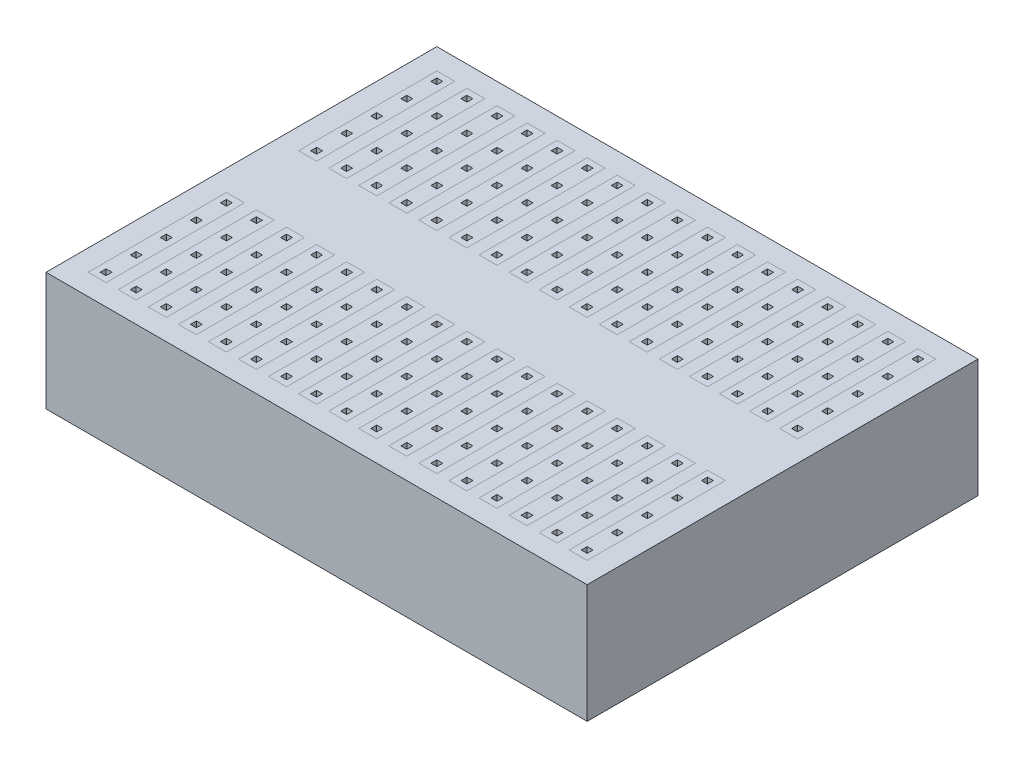
from build123d import *

# Parameters (mm, degrees)
SKETCH_PROTOBOARD_BODY_W        = 45.72
SKETCH_PROTOBOARD_BODY_H        = 33.02
PROTOBOARD_BODY_DEPTH           = 10
SKETCH_TERMINAL_STRIPS_W        = 1.52
SKETCH_TERMINAL_STRIPS_H        = 11.68
SPACE_FOR_TERMINAL_STRIPS_DEPTH = 8.4
SKETCH3_2_W                     = 1.52
SKETCH3_2_H                     = 11.68
TERMINAL_STRIPS_DEPTH           = 8.4
TERMINAL_STRIPS_2_DEPTH         = 8.4
TERMINAL_STRIPS_3_DEPTH         = 8.4
TERMINAL_STRIPS_4_DEPTH         = 8.4
TERMINAL_STRIPS_5_DEPTH         = 8.4
TERMINAL_STRIPS_6_DEPTH         = 8.4
TERMINAL_STRIPS_7_DEPTH         = 8.4
TERMINAL_STRIPS_8_DEPTH         = 8.4
TERMINAL_STRIPS_9_DEPTH         = 8.4
TERMINAL_STRIPS_10_DEPTH        = 8.4
TERMINAL_STRIPS_11_DEPTH        = 8.4
TERMINAL_STRIPS_12_DEPTH        = 8.4
TERMINAL_STRIPS_13_DEPTH        = 8.4
TERMINAL_STRIPS_14_DEPTH        = 8.4
TERMINAL_STRIPS_15_DEPTH        = 8.4
TERMINAL_STRIPS_16_DEPTH        = 8.4
TERMINAL_STRIPS_17_DEPTH        = 8.4
TERMINAL_STRIPS_18_DEPTH        = 8.4
TERMINAL_STRIPS_19_DEPTH        = 8.4
TERMINAL_STRIPS_20_DEPTH        = 8.4
TERMINAL_STRIPS_21_DEPTH        = 8.4
TERMINAL_STRIPS_22_DEPTH        = 8.4
TERMINAL_STRIPS_23_DEPTH        = 8.4
TERMINAL_STRIPS_24_DEPTH        = 8.4
TERMINAL_STRIPS_25_DEPTH        = 8.4
TERMINAL_STRIPS_26_DEPTH        = 8.4
TERMINAL_STRIPS_27_DEPTH        = 8.4
TERMINAL_STRIPS_28_DEPTH        = 8.4
TERMINAL_STRIPS_29_DEPTH        = 8.4
TERMINAL_STRIPS_30_DEPTH        = 8.4
TERMINAL_STRIPS_31_DEPTH        = 8.4
TERMINAL_STRIPS_32_DEPTH        = 8.4
TERMINAL_STRIPS_33_DEPTH        = 8.4
TERMINAL_STRIPS_34_DEPTH        = 8.4
SKETCH_PIN_HOLES_W              = 0.5
SKETCH_PIN_HOLES_H              = 0.5
PIN_HOLES_DEPTH                 = 7.9


with BuildPart() as part:
    # Sketch_ Protoboard Body → Protoboard Body (new body)
    with BuildSketch(Plane(origin=(0, 0, 0), x_dir=(1, 0, 0), z_dir=(0, 1, 0))):
        Rectangle(SKETCH_PROTOBOARD_BODY_W, SKETCH_PROTOBOARD_BODY_H)
    extrude(amount=-PROTOBOARD_BODY_DEPTH)

    # Sketch_ Terminal Strips → Space for Terminal Strips (cut)
    with BuildSketch(Plane(origin=(0, 0, 0), x_dir=(1, 0, 0), z_dir=(0, 1, 0))):
        with Locations((-17.78, -8.89)):
            Rectangle(SKETCH_TERMINAL_STRIPS_W, SKETCH_TERMINAL_STRIPS_H)
        with Locations((-20.32, -8.89)):
            Rectangle(SKETCH_TERMINAL_STRIPS_W, SKETCH_TERMINAL_STRIPS_H)
        with Locations((-15.24, -8.89)):
            Rectangle(SKETCH_TERMINAL_STRIPS_W, SKETCH_TERMINAL_STRIPS_H)
        with Locations((-12.7, -8.89)):
            Rectangle(SKETCH_TERMINAL_STRIPS_W, SKETCH_TERMINAL_STRIPS_H)
        with Locations((-10.16, -8.89)):
            Rectangle(SKETCH_TERMINAL_STRIPS_W, SKETCH_TERMINAL_STRIPS_H)
        with Locations((-7.62, -8.89)):
            Rectangle(SKETCH_TERMINAL_STRIPS_W, SKETCH_TERMINAL_STRIPS_H)
        with Locations((-5.08, -8.89)):
            Rectangle(SKETCH_TERMINAL_STRIPS_W, SKETCH_TERMINAL_STRIPS_H)
        with Locations((-2.54, -8.89)):
            Rectangle(SKETCH_TERMINAL_STRIPS_W, SKETCH_TERMINAL_STRIPS_H)
        with Locations((0, -8.89)):
            Rectangle(SKETCH_TERMINAL_STRIPS_W, SKETCH_TERMINAL_STRIPS_H)
        with Locations((2.54, -8.89)):
            Rectangle(SKETCH_TERMINAL_STRIPS_W, SKETCH_TERMINAL_STRIPS_H)
        with Locations((5.08, -8.89)):
            Rectangle(SKETCH_TERMINAL_STRIPS_W, SKETCH_TERMINAL_STRIPS_H)
        with Locations((7.62, -8.89)):
            Rectangle(SKETCH_TERMINAL_STRIPS_W, SKETCH_TERMINAL_STRIPS_H)
        with Locations((10.16, -8.89)):
            Rectangle(SKETCH_TERMINAL_STRIPS_W, SKETCH_TERMINAL_STRIPS_H)
        with Locations((12.7, -8.89)):
            Rectangle(SKETCH_TERMINAL_STRIPS_W, SKETCH_TERMINAL_STRIPS_H)
        with Locations((15.24, -8.89)):
            Rectangle(SKETCH_TERMINAL_STRIPS_W, SKETCH_TERMINAL_STRIPS_H)
        with Locations((17.78, -8.89)):
            Rectangle(SKETCH_TERMINAL_STRIPS_W, SKETCH_TERMINAL_STRIPS_H)
        with Locations((20.32, -8.89)):
            Rectangle(SKETCH_TERMINAL_STRIPS_W, SKETCH_TERMINAL_STRIPS_H)
        with Locations((-17.78, 8.89)):
            Rectangle(SKETCH_TERMINAL_STRIPS_W, SKETCH_TERMINAL_STRIPS_H)
        with Locations((-15.24, 8.89)):
            Rectangle(SKETCH_TERMINAL_STRIPS_W, SKETCH_TERMINAL_STRIPS_H)
        with Locations((-12.7, 8.89)):
            Rectangle(SKETCH_TERMINAL_STRIPS_W, SKETCH_TERMINAL_STRIPS_H)
        with Locations((-10.16, 8.89)):
            Rectangle(SKETCH_TERMINAL_STRIPS_W, SKETCH_TERMINAL_STRIPS_H)
        with Locations((-7.62, 8.89)):
            Rectangle(SKETCH_TERMINAL_STRIPS_W, SKETCH_TERMINAL_STRIPS_H)
        with Locations((-5.08, 8.89)):
            Rectangle(SKETCH_TERMINAL_STRIPS_W, SKETCH_TERMINAL_STRIPS_H)
        with Locations((-2.54, 8.89)):
            Rectangle(SKETCH_TERMINAL_STRIPS_W, SKETCH_TERMINAL_STRIPS_H)
        with Locations((0, 8.89)):
            Rectangle(SKETCH_TERMINAL_STRIPS_W, SKETCH_TERMINAL_STRIPS_H)
        with Locations((2.54, 8.89)):
            Rectangle(SKETCH_TERMINAL_STRIPS_W, SKETCH_TERMINAL_STRIPS_H)
        with Locations((5.08, 8.89)):
            Rectangle(SKETCH_TERMINAL_STRIPS_W, SKETCH_TERMINAL_STRIPS_H)
        with Locations((7.62, 8.89)):
            Rectangle(SKETCH_TERMINAL_STRIPS_W, SKETCH_TERMINAL_STRIPS_H)
        with Locations((10.16, 8.89)):
            Rectangle(SKETCH_TERMINAL_STRIPS_W, SKETCH_TERMINAL_STRIPS_H)
        with Locations((12.7, 8.89)):
            Rectangle(SKETCH_TERMINAL_STRIPS_W, SKETCH_TERMINAL_STRIPS_H)
        with Locations((15.24, 8.89)):
            Rectangle(SKETCH_TERMINAL_STRIPS_W, SKETCH_TERMINAL_STRIPS_H)
        with Locations((17.78, 8.89)):
            Rectangle(SKETCH_TERMINAL_STRIPS_W, SKETCH_TERMINAL_STRIPS_H)
        with Locations((20.32, 8.89)):
            Rectangle(SKETCH_TERMINAL_STRIPS_W, SKETCH_TERMINAL_STRIPS_H)
        with Locations((-20.32, 8.89)):
            Rectangle(SKETCH_TERMINAL_STRIPS_W, SKETCH_TERMINAL_STRIPS_H)
    extrude(amount=-SPACE_FOR_TERMINAL_STRIPS_DEPTH, mode=Mode.SUBTRACT)


with BuildPart() as body_2:
    # Sketch3_2 → Terminal Strips (new body)
    with BuildSketch(Plane(origin=(0, 0, 0), x_dir=(1, 0, 0), z_dir=(0, 1, 0))):
        with Locations((-17.78, -8.89)):
            Rectangle(SKETCH3_2_W, SKETCH3_2_H)
    extrude(amount=-TERMINAL_STRIPS_DEPTH)


with BuildPart() as body_3:
    # Sketch3_2 → Terminal Strips 2 (new body)
    with BuildSketch(Plane(origin=(0, 0, 0), x_dir=(1, 0, 0), z_dir=(0, 1, 0))):
        with Locations((-20.32, -8.89)):
            Rectangle(SKETCH3_2_W, SKETCH3_2_H)
    extrude(amount=-TERMINAL_STRIPS_2_DEPTH)


with BuildPart() as body_4:
    # Sketch3_2 → Terminal Strips 3 (new body)
    with BuildSketch(Plane(origin=(0, 0, 0), x_dir=(1, 0, 0), z_dir=(0, 1, 0))):
        with Locations((-15.24, -8.89)):
            Rectangle(SKETCH3_2_W, SKETCH3_2_H)
    extrude(amount=-TERMINAL_STRIPS_3_DEPTH)


with BuildPart() as body_5:
    # Sketch3_2 → Terminal Strips 4 (new body)
    with BuildSketch(Plane(origin=(0, 0, 0), x_dir=(1, 0, 0), z_dir=(0, 1, 0))):
        with Locations((-12.7, -8.89)):
            Rectangle(SKETCH3_2_W, SKETCH3_2_H)
    extrude(amount=-TERMINAL_STRIPS_4_DEPTH)


with BuildPart() as body_6:
    # Sketch3_2 → Terminal Strips 5 (new body)
    with BuildSketch(Plane(origin=(0, 0, 0), x_dir=(1, 0, 0), z_dir=(0, 1, 0))):
        with Locations((-10.16, -8.89)):
            Rectangle(SKETCH3_2_W, SKETCH3_2_H)
    extrude(amount=-TERMINAL_STRIPS_5_DEPTH)


with BuildPart() as body_7:
    # Sketch3_2 → Terminal Strips 6 (new body)
    with BuildSketch(Plane(origin=(0, 0, 0), x_dir=(1, 0, 0), z_dir=(0, 1, 0))):
        with Locations((-7.62, -8.89)):
            Rectangle(SKETCH3_2_W, SKETCH3_2_H)
    extrude(amount=-TERMINAL_STRIPS_6_DEPTH)


with BuildPart() as body_8:
    # Sketch3_2 → Terminal Strips 7 (new body)
    with BuildSketch(Plane(origin=(0, 0, 0), x_dir=(1, 0, 0), z_dir=(0, 1, 0))):
        with Locations((-5.08, -8.89)):
            Rectangle(SKETCH3_2_W, SKETCH3_2_H)
    extrude(amount=-TERMINAL_STRIPS_7_DEPTH)


with BuildPart() as body_9:
    # Sketch3_2 → Terminal Strips 8 (new body)
    with BuildSketch(Plane(origin=(0, 0, 0), x_dir=(1, 0, 0), z_dir=(0, 1, 0))):
        with Locations((-2.54, -8.89)):
            Rectangle(SKETCH3_2_W, SKETCH3_2_H)
    extrude(amount=-TERMINAL_STRIPS_8_DEPTH)


with BuildPart() as body_10:
    # Sketch3_2 → Terminal Strips 9 (new body)
    with BuildSketch(Plane(origin=(0, 0, 0), x_dir=(1, 0, 0), z_dir=(0, 1, 0))):
        with Locations((0, -8.89)):
            Rectangle(SKETCH3_2_W, SKETCH3_2_H)
    extrude(amount=-TERMINAL_STRIPS_9_DEPTH)


with BuildPart() as body_11:
    # Sketch3_2 → Terminal Strips 10 (new body)
    with BuildSketch(Plane(origin=(0, 0, 0), x_dir=(1, 0, 0), z_dir=(0, 1, 0))):
        with Locations((2.54, -8.89)):
            Rectangle(SKETCH3_2_W, SKETCH3_2_H)
    extrude(amount=-TERMINAL_STRIPS_10_DEPTH)


with BuildPart() as body_12:
    # Sketch3_2 → Terminal Strips 11 (new body)
    with BuildSketch(Plane(origin=(0, 0, 0), x_dir=(1, 0, 0), z_dir=(0, 1, 0))):
        with Locations((5.08, -8.89)):
            Rectangle(SKETCH3_2_W, SKETCH3_2_H)
    extrude(amount=-TERMINAL_STRIPS_11_DEPTH)


with BuildPart() as body_13:
    # Sketch3_2 → Terminal Strips 12 (new body)
    with BuildSketch(Plane(origin=(0, 0, 0), x_dir=(1, 0, 0), z_dir=(0, 1, 0))):
        with Locations((7.62, -8.89)):
            Rectangle(SKETCH3_2_W, SKETCH3_2_H)
    extrude(amount=-TERMINAL_STRIPS_12_DEPTH)


with BuildPart() as body_14:
    # Sketch3_2 → Terminal Strips 13 (new body)
    with BuildSketch(Plane(origin=(0, 0, 0), x_dir=(1, 0, 0), z_dir=(0, 1, 0))):
        with Locations((10.16, -8.89)):
            Rectangle(SKETCH3_2_W, SKETCH3_2_H)
    extrude(amount=-TERMINAL_STRIPS_13_DEPTH)


with BuildPart() as body_15:
    # Sketch3_2 → Terminal Strips 14 (new body)
    with BuildSketch(Plane(origin=(0, 0, 0), x_dir=(1, 0, 0), z_dir=(0, 1, 0))):
        with Locations((12.7, -8.89)):
            Rectangle(SKETCH3_2_W, SKETCH3_2_H)
    extrude(amount=-TERMINAL_STRIPS_14_DEPTH)


with BuildPart() as body_16:
    # Sketch3_2 → Terminal Strips 15 (new body)
    with BuildSketch(Plane(origin=(0, 0, 0), x_dir=(1, 0, 0), z_dir=(0, 1, 0))):
        with Locations((15.24, -8.89)):
            Rectangle(SKETCH3_2_W, SKETCH3_2_H)
    extrude(amount=-TERMINAL_STRIPS_15_DEPTH)


with BuildPart() as body_17:
    # Sketch3_2 → Terminal Strips 16 (new body)
    with BuildSketch(Plane(origin=(0, 0, 0), x_dir=(1, 0, 0), z_dir=(0, 1, 0))):
        with Locations((17.78, -8.89)):
            Rectangle(SKETCH3_2_W, SKETCH3_2_H)
    extrude(amount=-TERMINAL_STRIPS_16_DEPTH)


with BuildPart() as body_18:
    # Sketch3_2 → Terminal Strips 17 (new body)
    with BuildSketch(Plane(origin=(0, 0, 0), x_dir=(1, 0, 0), z_dir=(0, 1, 0))):
        with Locations((20.32, -8.89)):
            Rectangle(SKETCH3_2_W, SKETCH3_2_H)
    extrude(amount=-TERMINAL_STRIPS_17_DEPTH)


with BuildPart() as body_19:
    # Sketch3_2 → Terminal Strips 18 (new body)
    with BuildSketch(Plane(origin=(0, 0, 0), x_dir=(1, 0, 0), z_dir=(0, 1, 0))):
        with Locations((-17.78, 8.89)):
            Rectangle(SKETCH3_2_W, SKETCH3_2_H)
    extrude(amount=-TERMINAL_STRIPS_18_DEPTH)


with BuildPart() as body_20:
    # Sketch3_2 → Terminal Strips 19 (new body)
    with BuildSketch(Plane(origin=(0, 0, 0), x_dir=(1, 0, 0), z_dir=(0, 1, 0))):
        with Locations((-15.24, 8.89)):
            Rectangle(SKETCH3_2_W, SKETCH3_2_H)
    extrude(amount=-TERMINAL_STRIPS_19_DEPTH)


with BuildPart() as body_21:
    # Sketch3_2 → Terminal Strips 20 (new body)
    with BuildSketch(Plane(origin=(0, 0, 0), x_dir=(1, 0, 0), z_dir=(0, 1, 0))):
        with Locations((-12.7, 8.89)):
            Rectangle(SKETCH3_2_W, SKETCH3_2_H)
    extrude(amount=-TERMINAL_STRIPS_20_DEPTH)


with BuildPart() as body_22:
    # Sketch3_2 → Terminal Strips 21 (new body)
    with BuildSketch(Plane(origin=(0, 0, 0), x_dir=(1, 0, 0), z_dir=(0, 1, 0))):
        with Locations((-10.16, 8.89)):
            Rectangle(SKETCH3_2_W, SKETCH3_2_H)
    extrude(amount=-TERMINAL_STRIPS_21_DEPTH)


with BuildPart() as body_23:
    # Sketch3_2 → Terminal Strips 22 (new body)
    with BuildSketch(Plane(origin=(0, 0, 0), x_dir=(1, 0, 0), z_dir=(0, 1, 0))):
        with Locations((-7.62, 8.89)):
            Rectangle(SKETCH3_2_W, SKETCH3_2_H)
    extrude(amount=-TERMINAL_STRIPS_22_DEPTH)


with BuildPart() as body_24:
    # Sketch3_2 → Terminal Strips 23 (new body)
    with BuildSketch(Plane(origin=(0, 0, 0), x_dir=(1, 0, 0), z_dir=(0, 1, 0))):
        with Locations((-5.08, 8.89)):
            Rectangle(SKETCH3_2_W, SKETCH3_2_H)
    extrude(amount=-TERMINAL_STRIPS_23_DEPTH)


with BuildPart() as body_25:
    # Sketch3_2 → Terminal Strips 24 (new body)
    with BuildSketch(Plane(origin=(0, 0, 0), x_dir=(1, 0, 0), z_dir=(0, 1, 0))):
        with Locations((-2.54, 8.89)):
            Rectangle(SKETCH3_2_W, SKETCH3_2_H)
    extrude(amount=-TERMINAL_STRIPS_24_DEPTH)


with BuildPart() as body_26:
    # Sketch3_2 → Terminal Strips 25 (new body)
    with BuildSketch(Plane(origin=(0, 0, 0), x_dir=(1, 0, 0), z_dir=(0, 1, 0))):
        with Locations((0, 8.89)):
            Rectangle(SKETCH3_2_W, SKETCH3_2_H)
    extrude(amount=-TERMINAL_STRIPS_25_DEPTH)


with BuildPart() as body_27:
    # Sketch3_2 → Terminal Strips 26 (new body)
    with BuildSketch(Plane(origin=(0, 0, 0), x_dir=(1, 0, 0), z_dir=(0, 1, 0))):
        with Locations((2.54, 8.89)):
            Rectangle(SKETCH3_2_W, SKETCH3_2_H)
    extrude(amount=-TERMINAL_STRIPS_26_DEPTH)


with BuildPart() as body_28:
    # Sketch3_2 → Terminal Strips 27 (new body)
    with BuildSketch(Plane(origin=(0, 0, 0), x_dir=(1, 0, 0), z_dir=(0, 1, 0))):
        with Locations((5.08, 8.89)):
            Rectangle(SKETCH3_2_W, SKETCH3_2_H)
    extrude(amount=-TERMINAL_STRIPS_27_DEPTH)


with BuildPart() as body_29:
    # Sketch3_2 → Terminal Strips 28 (new body)
    with BuildSketch(Plane(origin=(0, 0, 0), x_dir=(1, 0, 0), z_dir=(0, 1, 0))):
        with Locations((7.62, 8.89)):
            Rectangle(SKETCH3_2_W, SKETCH3_2_H)
    extrude(amount=-TERMINAL_STRIPS_28_DEPTH)


with BuildPart() as body_30:
    # Sketch3_2 → Terminal Strips 29 (new body)
    with BuildSketch(Plane(origin=(0, 0, 0), x_dir=(1, 0, 0), z_dir=(0, 1, 0))):
        with Locations((10.16, 8.89)):
            Rectangle(SKETCH3_2_W, SKETCH3_2_H)
    extrude(amount=-TERMINAL_STRIPS_29_DEPTH)


with BuildPart() as body_31:
    # Sketch3_2 → Terminal Strips 30 (new body)
    with BuildSketch(Plane(origin=(0, 0, 0), x_dir=(1, 0, 0), z_dir=(0, 1, 0))):
        with Locations((12.7, 8.89)):
            Rectangle(SKETCH3_2_W, SKETCH3_2_H)
    extrude(amount=-TERMINAL_STRIPS_30_DEPTH)


with BuildPart() as body_32:
    # Sketch3_2 → Terminal Strips 31 (new body)
    with BuildSketch(Plane(origin=(0, 0, 0), x_dir=(1, 0, 0), z_dir=(0, 1, 0))):
        with Locations((15.24, 8.89)):
            Rectangle(SKETCH3_2_W, SKETCH3_2_H)
    extrude(amount=-TERMINAL_STRIPS_31_DEPTH)


with BuildPart() as body_33:
    # Sketch3_2 → Terminal Strips 32 (new body)
    with BuildSketch(Plane(origin=(0, 0, 0), x_dir=(1, 0, 0), z_dir=(0, 1, 0))):
        with Locations((17.78, 8.89)):
            Rectangle(SKETCH3_2_W, SKETCH3_2_H)
    extrude(amount=-TERMINAL_STRIPS_32_DEPTH)


with BuildPart() as body_34:
    # Sketch3_2 → Terminal Strips 33 (new body)
    with BuildSketch(Plane(origin=(0, 0, 0), x_dir=(1, 0, 0), z_dir=(0, 1, 0))):
        with Locations((20.32, 8.89)):
            Rectangle(SKETCH3_2_W, SKETCH3_2_H)
    extrude(amount=-TERMINAL_STRIPS_33_DEPTH)


with BuildPart() as body_35:
    # Sketch3_2 → Terminal Strips 34 (new body)
    with BuildSketch(Plane(origin=(0, 0, 0), x_dir=(1, 0, 0), z_dir=(0, 1, 0))):
        with Locations((-20.32, 8.89)):
            Rectangle(SKETCH3_2_W, SKETCH3_2_H)
    extrude(amount=-TERMINAL_STRIPS_34_DEPTH)


with BuildPart() as pin_holes_tool:
    # Sketch_ Pin Holes → Pin Holes (new body)
    with BuildSketch(Plane(origin=(0, 0, 0), x_dir=(1, 0, 0), z_dir=(0, 1, 0))):
        with Locations((-20.32, -13.97)):
            Rectangle(SKETCH_PIN_HOLES_W, SKETCH_PIN_HOLES_H)
        with Locations((-20.32, -11.43)):
            Rectangle(SKETCH_PIN_HOLES_W, SKETCH_PIN_HOLES_H)
        with Locations((-20.32, -8.89)):
            Rectangle(SKETCH_PIN_HOLES_W, SKETCH_PIN_HOLES_H)
        with Locations((-20.32, -6.35)):
            Rectangle(SKETCH_PIN_HOLES_W, SKETCH_PIN_HOLES_H)
        with Locations((-20.32, -3.81)):
            Rectangle(SKETCH_PIN_HOLES_W, SKETCH_PIN_HOLES_H)
        with Locations((-20.32, 3.81)):
            Rectangle(SKETCH_PIN_HOLES_W, SKETCH_PIN_HOLES_H)
        with Locations((-20.32, 6.35)):
            Rectangle(SKETCH_PIN_HOLES_W, SKETCH_PIN_HOLES_H)
        with Locations((-20.32, 8.89)):
            Rectangle(SKETCH_PIN_HOLES_W, SKETCH_PIN_HOLES_H)
        with Locations((-20.32, 11.43)):
            Rectangle(SKETCH_PIN_HOLES_W, SKETCH_PIN_HOLES_H)
        with Locations((-20.32, 13.97)):
            Rectangle(SKETCH_PIN_HOLES_W, SKETCH_PIN_HOLES_H)
        with Locations((-17.78, -13.97)):
            Rectangle(SKETCH_PIN_HOLES_W, SKETCH_PIN_HOLES_H)
        with Locations((-17.78, -11.43)):
            Rectangle(SKETCH_PIN_HOLES_W, SKETCH_PIN_HOLES_H)
        with Locations((-17.78, -8.89)):
            Rectangle(SKETCH_PIN_HOLES_W, SKETCH_PIN_HOLES_H)
        with Locations((-17.78, -6.35)):
            Rectangle(SKETCH_PIN_HOLES_W, SKETCH_PIN_HOLES_H)
        with Locations((-17.78, -3.81)):
            Rectangle(SKETCH_PIN_HOLES_W, SKETCH_PIN_HOLES_H)
        with Locations((-17.78, 3.81)):
            Rectangle(SKETCH_PIN_HOLES_W, SKETCH_PIN_HOLES_H)
        with Locations((-17.78, 6.35)):
            Rectangle(SKETCH_PIN_HOLES_W, SKETCH_PIN_HOLES_H)
        with Locations((-17.78, 8.89)):
            Rectangle(SKETCH_PIN_HOLES_W, SKETCH_PIN_HOLES_H)
        with Locations((-17.78, 11.43)):
            Rectangle(SKETCH_PIN_HOLES_W, SKETCH_PIN_HOLES_H)
        with Locations((-17.78, 13.97)):
            Rectangle(SKETCH_PIN_HOLES_W, SKETCH_PIN_HOLES_H)
        with Locations((-15.24, -13.97)):
            Rectangle(SKETCH_PIN_HOLES_W, SKETCH_PIN_HOLES_H)
        with Locations((-15.24, -11.43)):
            Rectangle(SKETCH_PIN_HOLES_W, SKETCH_PIN_HOLES_H)
        with Locations((-15.24, -8.89)):
            Rectangle(SKETCH_PIN_HOLES_W, SKETCH_PIN_HOLES_H)
        with Locations((-15.24, -6.35)):
            Rectangle(SKETCH_PIN_HOLES_W, SKETCH_PIN_HOLES_H)
        with Locations((-15.24, -3.81)):
            Rectangle(SKETCH_PIN_HOLES_W, SKETCH_PIN_HOLES_H)
        with Locations((-15.24, 3.81)):
            Rectangle(SKETCH_PIN_HOLES_W, SKETCH_PIN_HOLES_H)
        with Locations((-15.24, 6.35)):
            Rectangle(SKETCH_PIN_HOLES_W, SKETCH_PIN_HOLES_H)
        with Locations((-15.24, 8.89)):
            Rectangle(SKETCH_PIN_HOLES_W, SKETCH_PIN_HOLES_H)
        with Locations((-15.24, 11.43)):
            Rectangle(SKETCH_PIN_HOLES_W, SKETCH_PIN_HOLES_H)
        with Locations((-15.24, 13.97)):
            Rectangle(SKETCH_PIN_HOLES_W, SKETCH_PIN_HOLES_H)
        with Locations((-12.7, -13.97)):
            Rectangle(SKETCH_PIN_HOLES_W, SKETCH_PIN_HOLES_H)
        with Locations((-12.7, -11.43)):
            Rectangle(SKETCH_PIN_HOLES_W, SKETCH_PIN_HOLES_H)
        with Locations((-12.7, -8.89)):
            Rectangle(SKETCH_PIN_HOLES_W, SKETCH_PIN_HOLES_H)
        with Locations((-12.7, -6.35)):
            Rectangle(SKETCH_PIN_HOLES_W, SKETCH_PIN_HOLES_H)
        with Locations((-12.7, -3.81)):
            Rectangle(SKETCH_PIN_HOLES_W, SKETCH_PIN_HOLES_H)
        with Locations((-12.7, 3.81)):
            Rectangle(SKETCH_PIN_HOLES_W, SKETCH_PIN_HOLES_H)
        with Locations((-12.7, 6.35)):
            Rectangle(SKETCH_PIN_HOLES_W, SKETCH_PIN_HOLES_H)
        with Locations((-12.7, 8.89)):
            Rectangle(SKETCH_PIN_HOLES_W, SKETCH_PIN_HOLES_H)
        with Locations((-12.7, 11.43)):
            Rectangle(SKETCH_PIN_HOLES_W, SKETCH_PIN_HOLES_H)
        with Locations((-12.7, 13.97)):
            Rectangle(SKETCH_PIN_HOLES_W, SKETCH_PIN_HOLES_H)
        with Locations((-10.16, -13.97)):
            Rectangle(SKETCH_PIN_HOLES_W, SKETCH_PIN_HOLES_H)
        with Locations((-10.16, -11.43)):
            Rectangle(SKETCH_PIN_HOLES_W, SKETCH_PIN_HOLES_H)
        with Locations((-10.16, -8.89)):
            Rectangle(SKETCH_PIN_HOLES_W, SKETCH_PIN_HOLES_H)
        with Locations((-10.16, -6.35)):
            Rectangle(SKETCH_PIN_HOLES_W, SKETCH_PIN_HOLES_H)
        with Locations((-10.16, -3.81)):
            Rectangle(SKETCH_PIN_HOLES_W, SKETCH_PIN_HOLES_H)
        with Locations((-10.16, 3.81)):
            Rectangle(SKETCH_PIN_HOLES_W, SKETCH_PIN_HOLES_H)
        with Locations((-10.16, 6.35)):
            Rectangle(SKETCH_PIN_HOLES_W, SKETCH_PIN_HOLES_H)
        with Locations((-10.16, 8.89)):
            Rectangle(SKETCH_PIN_HOLES_W, SKETCH_PIN_HOLES_H)
        with Locations((-10.16, 11.43)):
            Rectangle(SKETCH_PIN_HOLES_W, SKETCH_PIN_HOLES_H)
        with Locations((-10.16, 13.97)):
            Rectangle(SKETCH_PIN_HOLES_W, SKETCH_PIN_HOLES_H)
        with Locations((-7.62, -13.97)):
            Rectangle(SKETCH_PIN_HOLES_W, SKETCH_PIN_HOLES_H)
        with Locations((-7.62, -11.43)):
            Rectangle(SKETCH_PIN_HOLES_W, SKETCH_PIN_HOLES_H)
        with Locations((-7.62, -8.89)):
            Rectangle(SKETCH_PIN_HOLES_W, SKETCH_PIN_HOLES_H)
        with Locations((-7.62, -6.35)):
            Rectangle(SKETCH_PIN_HOLES_W, SKETCH_PIN_HOLES_H)
        with Locations((-7.62, -3.81)):
            Rectangle(SKETCH_PIN_HOLES_W, SKETCH_PIN_HOLES_H)
        with Locations((-7.62, 3.81)):
            Rectangle(SKETCH_PIN_HOLES_W, SKETCH_PIN_HOLES_H)
        with Locations((-7.62, 6.35)):
            Rectangle(SKETCH_PIN_HOLES_W, SKETCH_PIN_HOLES_H)
        with Locations((-7.62, 8.89)):
            Rectangle(SKETCH_PIN_HOLES_W, SKETCH_PIN_HOLES_H)
        with Locations((-7.62, 11.43)):
            Rectangle(SKETCH_PIN_HOLES_W, SKETCH_PIN_HOLES_H)
        with Locations((-7.62, 13.97)):
            Rectangle(SKETCH_PIN_HOLES_W, SKETCH_PIN_HOLES_H)
        with Locations((-5.08, -13.97)):
            Rectangle(SKETCH_PIN_HOLES_W, SKETCH_PIN_HOLES_H)
        with Locations((-5.08, -11.43)):
            Rectangle(SKETCH_PIN_HOLES_W, SKETCH_PIN_HOLES_H)
        with Locations((-5.08, -8.89)):
            Rectangle(SKETCH_PIN_HOLES_W, SKETCH_PIN_HOLES_H)
        with Locations((-5.08, -6.35)):
            Rectangle(SKETCH_PIN_HOLES_W, SKETCH_PIN_HOLES_H)
        with Locations((-5.08, -3.81)):
            Rectangle(SKETCH_PIN_HOLES_W, SKETCH_PIN_HOLES_H)
        with Locations((-5.08, 3.81)):
            Rectangle(SKETCH_PIN_HOLES_W, SKETCH_PIN_HOLES_H)
        with Locations((-5.08, 6.35)):
            Rectangle(SKETCH_PIN_HOLES_W, SKETCH_PIN_HOLES_H)
        with Locations((-5.08, 8.89)):
            Rectangle(SKETCH_PIN_HOLES_W, SKETCH_PIN_HOLES_H)
        with Locations((-5.08, 11.43)):
            Rectangle(SKETCH_PIN_HOLES_W, SKETCH_PIN_HOLES_H)
        with Locations((-5.08, 13.97)):
            Rectangle(SKETCH_PIN_HOLES_W, SKETCH_PIN_HOLES_H)
        with Locations((-2.54, -13.97)):
            Rectangle(SKETCH_PIN_HOLES_W, SKETCH_PIN_HOLES_H)
        with Locations((-2.54, -11.43)):
            Rectangle(SKETCH_PIN_HOLES_W, SKETCH_PIN_HOLES_H)
        with Locations((-2.54, -8.89)):
            Rectangle(SKETCH_PIN_HOLES_W, SKETCH_PIN_HOLES_H)
        with Locations((-2.54, -6.35)):
            Rectangle(SKETCH_PIN_HOLES_W, SKETCH_PIN_HOLES_H)
        with Locations((-2.54, -3.81)):
            Rectangle(SKETCH_PIN_HOLES_W, SKETCH_PIN_HOLES_H)
        with Locations((-2.54, 3.81)):
            Rectangle(SKETCH_PIN_HOLES_W, SKETCH_PIN_HOLES_H)
        with Locations((-2.54, 6.35)):
            Rectangle(SKETCH_PIN_HOLES_W, SKETCH_PIN_HOLES_H)
        with Locations((-2.54, 8.89)):
            Rectangle(SKETCH_PIN_HOLES_W, SKETCH_PIN_HOLES_H)
        with Locations((-2.54, 11.43)):
            Rectangle(SKETCH_PIN_HOLES_W, SKETCH_PIN_HOLES_H)
        with Locations((-2.54, 13.97)):
            Rectangle(SKETCH_PIN_HOLES_W, SKETCH_PIN_HOLES_H)
        with Locations((0, -13.97)):
            Rectangle(SKETCH_PIN_HOLES_W, SKETCH_PIN_HOLES_H)
        with Locations((0, -11.43)):
            Rectangle(SKETCH_PIN_HOLES_W, SKETCH_PIN_HOLES_H)
        with Locations((0, -8.89)):
            Rectangle(SKETCH_PIN_HOLES_W, SKETCH_PIN_HOLES_H)
        with Locations((0, -6.35)):
            Rectangle(SKETCH_PIN_HOLES_W, SKETCH_PIN_HOLES_H)
        with Locations((0, -3.81)):
            Rectangle(SKETCH_PIN_HOLES_W, SKETCH_PIN_HOLES_H)
        with Locations((0, 3.81)):
            Rectangle(SKETCH_PIN_HOLES_W, SKETCH_PIN_HOLES_H)
        with Locations((0, 6.35)):
            Rectangle(SKETCH_PIN_HOLES_W, SKETCH_PIN_HOLES_H)
        with Locations((0, 8.89)):
            Rectangle(SKETCH_PIN_HOLES_W, SKETCH_PIN_HOLES_H)
        with Locations((0, 11.43)):
            Rectangle(SKETCH_PIN_HOLES_W, SKETCH_PIN_HOLES_H)
        with Locations((0, 13.97)):
            Rectangle(SKETCH_PIN_HOLES_W, SKETCH_PIN_HOLES_H)
        with Locations((2.54, -13.97)):
            Rectangle(SKETCH_PIN_HOLES_W, SKETCH_PIN_HOLES_H)
        with Locations((2.54, -11.43)):
            Rectangle(SKETCH_PIN_HOLES_W, SKETCH_PIN_HOLES_H)
        with Locations((2.54, -8.89)):
            Rectangle(SKETCH_PIN_HOLES_W, SKETCH_PIN_HOLES_H)
        with Locations((2.54, -6.35)):
            Rectangle(SKETCH_PIN_HOLES_W, SKETCH_PIN_HOLES_H)
        with Locations((2.54, -3.81)):
            Rectangle(SKETCH_PIN_HOLES_W, SKETCH_PIN_HOLES_H)
        with Locations((2.54, 3.81)):
            Rectangle(SKETCH_PIN_HOLES_W, SKETCH_PIN_HOLES_H)
        with Locations((2.54, 6.35)):
            Rectangle(SKETCH_PIN_HOLES_W, SKETCH_PIN_HOLES_H)
        with Locations((2.54, 8.89)):
            Rectangle(SKETCH_PIN_HOLES_W, SKETCH_PIN_HOLES_H)
        with Locations((2.54, 11.43)):
            Rectangle(SKETCH_PIN_HOLES_W, SKETCH_PIN_HOLES_H)
        with Locations((2.54, 13.97)):
            Rectangle(SKETCH_PIN_HOLES_W, SKETCH_PIN_HOLES_H)
        with Locations((5.08, -13.97)):
            Rectangle(SKETCH_PIN_HOLES_W, SKETCH_PIN_HOLES_H)
        with Locations((5.08, -11.43)):
            Rectangle(SKETCH_PIN_HOLES_W, SKETCH_PIN_HOLES_H)
        with Locations((5.08, -8.89)):
            Rectangle(SKETCH_PIN_HOLES_W, SKETCH_PIN_HOLES_H)
        with Locations((5.08, -6.35)):
            Rectangle(SKETCH_PIN_HOLES_W, SKETCH_PIN_HOLES_H)
        with Locations((5.08, -3.81)):
            Rectangle(SKETCH_PIN_HOLES_W, SKETCH_PIN_HOLES_H)
        with Locations((5.08, 3.81)):
            Rectangle(SKETCH_PIN_HOLES_W, SKETCH_PIN_HOLES_H)
        with Locations((5.08, 6.35)):
            Rectangle(SKETCH_PIN_HOLES_W, SKETCH_PIN_HOLES_H)
        with Locations((5.08, 8.89)):
            Rectangle(SKETCH_PIN_HOLES_W, SKETCH_PIN_HOLES_H)
        with Locations((5.08, 11.43)):
            Rectangle(SKETCH_PIN_HOLES_W, SKETCH_PIN_HOLES_H)
        with Locations((5.08, 13.97)):
            Rectangle(SKETCH_PIN_HOLES_W, SKETCH_PIN_HOLES_H)
        with Locations((7.62, -13.97)):
            Rectangle(SKETCH_PIN_HOLES_W, SKETCH_PIN_HOLES_H)
        with Locations((7.62, -11.43)):
            Rectangle(SKETCH_PIN_HOLES_W, SKETCH_PIN_HOLES_H)
        with Locations((7.62, -8.89)):
            Rectangle(SKETCH_PIN_HOLES_W, SKETCH_PIN_HOLES_H)
        with Locations((7.62, -6.35)):
            Rectangle(SKETCH_PIN_HOLES_W, SKETCH_PIN_HOLES_H)
        with Locations((7.62, -3.81)):
            Rectangle(SKETCH_PIN_HOLES_W, SKETCH_PIN_HOLES_H)
        with Locations((7.62, 3.81)):
            Rectangle(SKETCH_PIN_HOLES_W, SKETCH_PIN_HOLES_H)
        with Locations((7.62, 6.35)):
            Rectangle(SKETCH_PIN_HOLES_W, SKETCH_PIN_HOLES_H)
        with Locations((7.62, 8.89)):
            Rectangle(SKETCH_PIN_HOLES_W, SKETCH_PIN_HOLES_H)
        with Locations((7.62, 11.43)):
            Rectangle(SKETCH_PIN_HOLES_W, SKETCH_PIN_HOLES_H)
        with Locations((7.62, 13.97)):
            Rectangle(SKETCH_PIN_HOLES_W, SKETCH_PIN_HOLES_H)
        with Locations((10.16, -13.97)):
            Rectangle(SKETCH_PIN_HOLES_W, SKETCH_PIN_HOLES_H)
        with Locations((10.16, -11.43)):
            Rectangle(SKETCH_PIN_HOLES_W, SKETCH_PIN_HOLES_H)
        with Locations((10.16, -8.89)):
            Rectangle(SKETCH_PIN_HOLES_W, SKETCH_PIN_HOLES_H)
        with Locations((10.16, -6.35)):
            Rectangle(SKETCH_PIN_HOLES_W, SKETCH_PIN_HOLES_H)
        with Locations((10.16, -3.81)):
            Rectangle(SKETCH_PIN_HOLES_W, SKETCH_PIN_HOLES_H)
        with Locations((10.16, 3.81)):
            Rectangle(SKETCH_PIN_HOLES_W, SKETCH_PIN_HOLES_H)
        with Locations((10.16, 6.35)):
            Rectangle(SKETCH_PIN_HOLES_W, SKETCH_PIN_HOLES_H)
        with Locations((10.16, 8.89)):
            Rectangle(SKETCH_PIN_HOLES_W, SKETCH_PIN_HOLES_H)
        with Locations((10.16, 11.43)):
            Rectangle(SKETCH_PIN_HOLES_W, SKETCH_PIN_HOLES_H)
        with Locations((10.16, 13.97)):
            Rectangle(SKETCH_PIN_HOLES_W, SKETCH_PIN_HOLES_H)
        with Locations((12.7, -13.97)):
            Rectangle(SKETCH_PIN_HOLES_W, SKETCH_PIN_HOLES_H)
        with Locations((12.7, -11.43)):
            Rectangle(SKETCH_PIN_HOLES_W, SKETCH_PIN_HOLES_H)
        with Locations((12.7, -8.89)):
            Rectangle(SKETCH_PIN_HOLES_W, SKETCH_PIN_HOLES_H)
        with Locations((12.7, -6.35)):
            Rectangle(SKETCH_PIN_HOLES_W, SKETCH_PIN_HOLES_H)
        with Locations((12.7, -3.81)):
            Rectangle(SKETCH_PIN_HOLES_W, SKETCH_PIN_HOLES_H)
        with Locations((12.7, 3.81)):
            Rectangle(SKETCH_PIN_HOLES_W, SKETCH_PIN_HOLES_H)
        with Locations((12.7, 6.35)):
            Rectangle(SKETCH_PIN_HOLES_W, SKETCH_PIN_HOLES_H)
        with Locations((12.7, 8.89)):
            Rectangle(SKETCH_PIN_HOLES_W, SKETCH_PIN_HOLES_H)
        with Locations((12.7, 11.43)):
            Rectangle(SKETCH_PIN_HOLES_W, SKETCH_PIN_HOLES_H)
        with Locations((12.7, 13.97)):
            Rectangle(SKETCH_PIN_HOLES_W, SKETCH_PIN_HOLES_H)
        with Locations((15.24, -13.97)):
            Rectangle(SKETCH_PIN_HOLES_W, SKETCH_PIN_HOLES_H)
        with Locations((15.24, -11.43)):
            Rectangle(SKETCH_PIN_HOLES_W, SKETCH_PIN_HOLES_H)
        with Locations((15.24, -8.89)):
            Rectangle(SKETCH_PIN_HOLES_W, SKETCH_PIN_HOLES_H)
        with Locations((15.24, -6.35)):
            Rectangle(SKETCH_PIN_HOLES_W, SKETCH_PIN_HOLES_H)
        with Locations((15.24, -3.81)):
            Rectangle(SKETCH_PIN_HOLES_W, SKETCH_PIN_HOLES_H)
        with Locations((15.24, 3.81)):
            Rectangle(SKETCH_PIN_HOLES_W, SKETCH_PIN_HOLES_H)
        with Locations((15.24, 6.35)):
            Rectangle(SKETCH_PIN_HOLES_W, SKETCH_PIN_HOLES_H)
        with Locations((15.24, 8.89)):
            Rectangle(SKETCH_PIN_HOLES_W, SKETCH_PIN_HOLES_H)
        with Locations((15.24, 11.43)):
            Rectangle(SKETCH_PIN_HOLES_W, SKETCH_PIN_HOLES_H)
        with Locations((15.24, 13.97)):
            Rectangle(SKETCH_PIN_HOLES_W, SKETCH_PIN_HOLES_H)
        with Locations((17.78, -13.97)):
            Rectangle(SKETCH_PIN_HOLES_W, SKETCH_PIN_HOLES_H)
        with Locations((17.78, -11.43)):
            Rectangle(SKETCH_PIN_HOLES_W, SKETCH_PIN_HOLES_H)
        with Locations((17.78, -8.89)):
            Rectangle(SKETCH_PIN_HOLES_W, SKETCH_PIN_HOLES_H)
        with Locations((17.78, -6.35)):
            Rectangle(SKETCH_PIN_HOLES_W, SKETCH_PIN_HOLES_H)
        with Locations((17.78, -3.81)):
            Rectangle(SKETCH_PIN_HOLES_W, SKETCH_PIN_HOLES_H)
        with Locations((17.78, 3.81)):
            Rectangle(SKETCH_PIN_HOLES_W, SKETCH_PIN_HOLES_H)
        with Locations((17.78, 6.35)):
            Rectangle(SKETCH_PIN_HOLES_W, SKETCH_PIN_HOLES_H)
        with Locations((17.78, 8.89)):
            Rectangle(SKETCH_PIN_HOLES_W, SKETCH_PIN_HOLES_H)
        with Locations((17.78, 11.43)):
            Rectangle(SKETCH_PIN_HOLES_W, SKETCH_PIN_HOLES_H)
        with Locations((17.78, 13.97)):
            Rectangle(SKETCH_PIN_HOLES_W, SKETCH_PIN_HOLES_H)
        with Locations((20.32, -13.97)):
            Rectangle(SKETCH_PIN_HOLES_W, SKETCH_PIN_HOLES_H)
        with Locations((20.32, -11.43)):
            Rectangle(SKETCH_PIN_HOLES_W, SKETCH_PIN_HOLES_H)
        with Locations((20.32, -8.89)):
            Rectangle(SKETCH_PIN_HOLES_W, SKETCH_PIN_HOLES_H)
        with Locations((20.32, -6.35)):
            Rectangle(SKETCH_PIN_HOLES_W, SKETCH_PIN_HOLES_H)
        with Locations((20.32, -3.81)):
            Rectangle(SKETCH_PIN_HOLES_W, SKETCH_PIN_HOLES_H)
        with Locations((20.32, 3.81)):
            Rectangle(SKETCH_PIN_HOLES_W, SKETCH_PIN_HOLES_H)
        with Locations((20.32, 6.35)):
            Rectangle(SKETCH_PIN_HOLES_W, SKETCH_PIN_HOLES_H)
        with Locations((20.32, 8.89)):
            Rectangle(SKETCH_PIN_HOLES_W, SKETCH_PIN_HOLES_H)
        with Locations((20.32, 11.43)):
            Rectangle(SKETCH_PIN_HOLES_W, SKETCH_PIN_HOLES_H)
        with Locations((20.32, 13.97)):
            Rectangle(SKETCH_PIN_HOLES_W, SKETCH_PIN_HOLES_H)
    extrude(amount=-PIN_HOLES_DEPTH)


with BuildPart() as body_2_1:
    add(body_2.part)

    # Pin Holes: cut by pin_holes_tool
    add(pin_holes_tool.part, mode=Mode.SUBTRACT)


with BuildPart() as body_3_1:
    add(body_3.part)

    # Pin Holes: cut by pin_holes_tool
    add(pin_holes_tool.part, mode=Mode.SUBTRACT)


with BuildPart() as body_4_1:
    add(body_4.part)

    # Pin Holes: cut by pin_holes_tool
    add(pin_holes_tool.part, mode=Mode.SUBTRACT)


with BuildPart() as body_5_1:
    add(body_5.part)

    # Pin Holes: cut by pin_holes_tool
    add(pin_holes_tool.part, mode=Mode.SUBTRACT)


with BuildPart() as body_6_1:
    add(body_6.part)

    # Pin Holes: cut by pin_holes_tool
    add(pin_holes_tool.part, mode=Mode.SUBTRACT)


with BuildPart() as body_7_1:
    add(body_7.part)

    # Pin Holes: cut by pin_holes_tool
    add(pin_holes_tool.part, mode=Mode.SUBTRACT)


with BuildPart() as body_8_1:
    add(body_8.part)

    # Pin Holes: cut by pin_holes_tool
    add(pin_holes_tool.part, mode=Mode.SUBTRACT)


with BuildPart() as body_9_1:
    add(body_9.part)

    # Pin Holes: cut by pin_holes_tool
    add(pin_holes_tool.part, mode=Mode.SUBTRACT)


with BuildPart() as body_10_1:
    add(body_10.part)

    # Pin Holes: cut by pin_holes_tool
    add(pin_holes_tool.part, mode=Mode.SUBTRACT)


with BuildPart() as body_11_1:
    add(body_11.part)

    # Pin Holes: cut by pin_holes_tool
    add(pin_holes_tool.part, mode=Mode.SUBTRACT)


with BuildPart() as body_12_1:
    add(body_12.part)

    # Pin Holes: cut by pin_holes_tool
    add(pin_holes_tool.part, mode=Mode.SUBTRACT)


with BuildPart() as body_13_1:
    add(body_13.part)

    # Pin Holes: cut by pin_holes_tool
    add(pin_holes_tool.part, mode=Mode.SUBTRACT)


with BuildPart() as body_14_1:
    add(body_14.part)

    # Pin Holes: cut by pin_holes_tool
    add(pin_holes_tool.part, mode=Mode.SUBTRACT)


with BuildPart() as body_15_1:
    add(body_15.part)

    # Pin Holes: cut by pin_holes_tool
    add(pin_holes_tool.part, mode=Mode.SUBTRACT)


with BuildPart() as body_16_1:
    add(body_16.part)

    # Pin Holes: cut by pin_holes_tool
    add(pin_holes_tool.part, mode=Mode.SUBTRACT)


with BuildPart() as body_17_1:
    add(body_17.part)

    # Pin Holes: cut by pin_holes_tool
    add(pin_holes_tool.part, mode=Mode.SUBTRACT)


with BuildPart() as body_18_1:
    add(body_18.part)

    # Pin Holes: cut by pin_holes_tool
    add(pin_holes_tool.part, mode=Mode.SUBTRACT)


with BuildPart() as body_19_1:
    add(body_19.part)

    # Pin Holes: cut by pin_holes_tool
    add(pin_holes_tool.part, mode=Mode.SUBTRACT)


with BuildPart() as body_20_1:
    add(body_20.part)

    # Pin Holes: cut by pin_holes_tool
    add(pin_holes_tool.part, mode=Mode.SUBTRACT)


with BuildPart() as body_21_1:
    add(body_21.part)

    # Pin Holes: cut by pin_holes_tool
    add(pin_holes_tool.part, mode=Mode.SUBTRACT)


with BuildPart() as body_22_1:
    add(body_22.part)

    # Pin Holes: cut by pin_holes_tool
    add(pin_holes_tool.part, mode=Mode.SUBTRACT)


with BuildPart() as body_23_1:
    add(body_23.part)

    # Pin Holes: cut by pin_holes_tool
    add(pin_holes_tool.part, mode=Mode.SUBTRACT)


with BuildPart() as body_24_1:
    add(body_24.part)

    # Pin Holes: cut by pin_holes_tool
    add(pin_holes_tool.part, mode=Mode.SUBTRACT)


with BuildPart() as body_25_1:
    add(body_25.part)

    # Pin Holes: cut by pin_holes_tool
    add(pin_holes_tool.part, mode=Mode.SUBTRACT)


with BuildPart() as body_26_1:
    add(body_26.part)

    # Pin Holes: cut by pin_holes_tool
    add(pin_holes_tool.part, mode=Mode.SUBTRACT)


with BuildPart() as body_27_1:
    add(body_27.part)

    # Pin Holes: cut by pin_holes_tool
    add(pin_holes_tool.part, mode=Mode.SUBTRACT)


with BuildPart() as body_28_1:
    add(body_28.part)

    # Pin Holes: cut by pin_holes_tool
    add(pin_holes_tool.part, mode=Mode.SUBTRACT)


with BuildPart() as body_29_1:
    add(body_29.part)

    # Pin Holes: cut by pin_holes_tool
    add(pin_holes_tool.part, mode=Mode.SUBTRACT)


with BuildPart() as body_30_1:
    add(body_30.part)

    # Pin Holes: cut by pin_holes_tool
    add(pin_holes_tool.part, mode=Mode.SUBTRACT)


with BuildPart() as body_31_1:
    add(body_31.part)

    # Pin Holes: cut by pin_holes_tool
    add(pin_holes_tool.part, mode=Mode.SUBTRACT)


with BuildPart() as body_32_1:
    add(body_32.part)

    # Pin Holes: cut by pin_holes_tool
    add(pin_holes_tool.part, mode=Mode.SUBTRACT)


with BuildPart() as body_33_1:
    add(body_33.part)

    # Pin Holes: cut by pin_holes_tool
    add(pin_holes_tool.part, mode=Mode.SUBTRACT)


with BuildPart() as body_34_1:
    add(body_34.part)

    # Pin Holes: cut by pin_holes_tool
    add(pin_holes_tool.part, mode=Mode.SUBTRACT)


with BuildPart() as body_35_1:
    add(body_35.part)

    # Pin Holes: cut by pin_holes_tool
    add(pin_holes_tool.part, mode=Mode.SUBTRACT)


solid = Compound([part.part, body_2_1.part, body_3_1.part, body_4_1.part, body_5_1.part, body_6_1.part, body_7_1.part, body_8_1.part, body_9_1.part, body_10_1.part, body_11_1.part, body_12_1.part, body_13_1.part, body_14_1.part, body_15_1.part, body_16_1.part, body_17_1.part, body_18_1.part, body_19_1.part, body_20_1.part, body_21_1.part, body_22_1.part, body_23_1.part, body_24_1.part, body_25_1.part, body_26_1.part, body_27_1.part, body_28_1.part, body_29_1.part, body_30_1.part, body_31_1.part, body_32_1.part, body_33_1.part, body_34_1.part, body_35_1.part])
